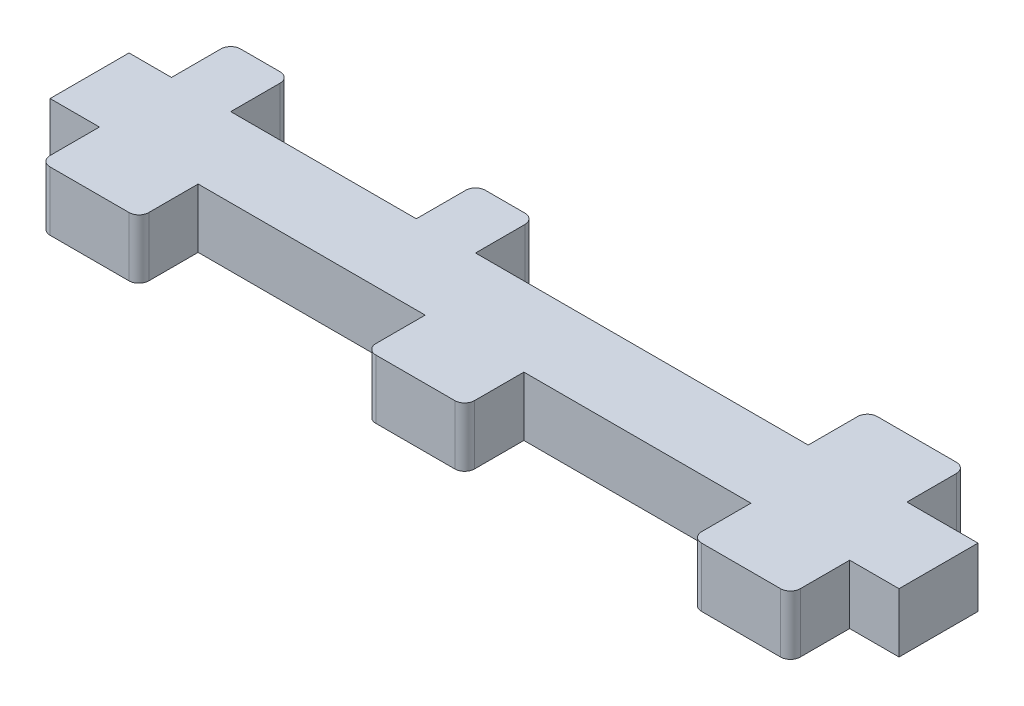
from build123d import *

# Parameters (mm, degrees)
SKETCH1_W               = 86
SKETCH1_H               = 8
BOSS_EXTRUDE1_DEPTH     = 6
SKETCH234_W             = 10
SKETCH234_H             = 6
BOSS_EXTRUDE234_DEPTH   = 6
FILLET134_R             = 1
SKETCH2341_W            = 10
SKETCH2341_H            = 6
BOSS_EXTRUDE2341_DEPTH  = 6
FILLET1341_R            = 1
SKETCH2342_W            = 10
SKETCH2342_H            = 6
BOSS_EXTRUDE2342_DEPTH  = 6
FILLET1342_R            = 1
SKETCH2343_W            = 10
SKETCH2343_H            = 6
BOSS_EXTRUDE2343_DEPTH  = 6
FILLET1343_R            = 1
SKETCH2348_W            = 6
SKETCH2348_H            = 6
BOSS_EXTRUDE2348_DEPTH  = 6
FILLET1348_R            = 1
SKETCH23410_W           = 6
SKETCH23410_H           = 6
BOSS_EXTRUDE23410_DEPTH = 6
FILLET13410_R           = 1


with BuildPart() as part:
    # Sketch1 → Boss-Extrude1 (new body)
    with BuildSketch(Plane(origin=(0, 0, 0), x_dir=(1, 0, 0), z_dir=(0, 1, 0))):
        with Locations((43, 4)):
            Rectangle(SKETCH1_W, SKETCH1_H)
    extrude(amount=BOSS_EXTRUDE1_DEPTH)

    # Sketch234 → Boss-Extrude234 (add)
    with BuildSketch(Plane(origin=(9.232221392, 0, 0), x_dir=(1, 0, 0), z_dir=(0, 0, 1))):
        with Locations((0.767778608, 3)):
            Rectangle(SKETCH234_W, SKETCH234_H)
    extrude(amount=BOSS_EXTRUDE234_DEPTH)

    # Fillet134
    fillet134_edges = [part.edges().sort_by_distance(p)[0] for p in [
        (5, 3, 6),
        (15, 3, 6),
    ]]
    fillet(fillet134_edges, radius=FILLET134_R)

    # Sketch2341 → Boss-Extrude2341 (add)
    with BuildSketch(Plane(origin=(42.232221392, 0, 0), x_dir=(1, 0, 0), z_dir=(0, 0, 1))):
        with Locations((0.767778608, 3)):
            Rectangle(SKETCH2341_W, SKETCH2341_H)
    extrude(amount=BOSS_EXTRUDE2341_DEPTH)

    # Fillet1341
    fillet1341_edges = [part.edges().sort_by_distance(p)[0] for p in [
        (48, 3, 6),
        (38, 3, 6),
    ]]
    fillet(fillet1341_edges, radius=FILLET1341_R)

    # Sketch2342 → Boss-Extrude2342 (add)
    with BuildSketch(Plane(origin=(75.232221392, 0, 0), x_dir=(1, 0, 0), z_dir=(0, 0, 1))):
        with Locations((0.767778608, 3)):
            Rectangle(SKETCH2342_W, SKETCH2342_H)
    extrude(amount=BOSS_EXTRUDE2342_DEPTH)

    # Fillet1342
    fillet1342_edges = [part.edges().sort_by_distance(p)[0] for p in [
        (81, 3, 6),
        (71, 3, 6),
    ]]
    fillet(fillet1342_edges, radius=FILLET1342_R)

    # Sketch2343 → Boss-Extrude2343 (add)
    with BuildSketch(Plane(origin=(73.032221392, 6, -8), x_dir=(1, 0, 0), z_dir=(0, 0, -1))):
        with Locations((0.767778608, 3)):
            Rectangle(SKETCH2343_W, SKETCH2343_H)
    extrude(amount=BOSS_EXTRUDE2343_DEPTH)

    # Fillet1343
    fillet1343_edges = [part.edges().sort_by_distance(p)[0] for p in [
        (68.8, 3, -14),
        (78.8, 3, -14),
    ]]
    fillet(fillet1343_edges, radius=FILLET1343_R)

    # Sketch2348 → Boss-Extrude2348 (add)
    with BuildSketch(Plane(origin=(31.332221392, 6, -8), x_dir=(1, 0, 0), z_dir=(0, 0, -1))):
        with Locations((0.767778608, 3)):
            Rectangle(SKETCH2348_W, SKETCH2348_H)
    extrude(amount=BOSS_EXTRUDE2348_DEPTH)

    # Fillet1348
    fillet1348_edges = [part.edges().sort_by_distance(p)[0] for p in [
        (35.1, 3, -14),
        (29.1, 3, -14),
    ]]
    fillet(fillet1348_edges, radius=FILLET1348_R)

    # Sketch23410 → Boss-Extrude23410 (add)
    with BuildSketch(Plane(origin=(6.532221392, 6, -8), x_dir=(1, 0, 0), z_dir=(0, 0, -1))):
        with Locations((0.767778608, 3)):
            Rectangle(SKETCH23410_W, SKETCH23410_H)
    extrude(amount=BOSS_EXTRUDE23410_DEPTH)

    # Fillet13410
    fillet13410_edges = [part.edges().sort_by_distance(p)[0] for p in [
        (10.3, 3, -14),
        (4.3, 3, -14),
    ]]
    fillet(fillet13410_edges, radius=FILLET13410_R)


solid = part.part
